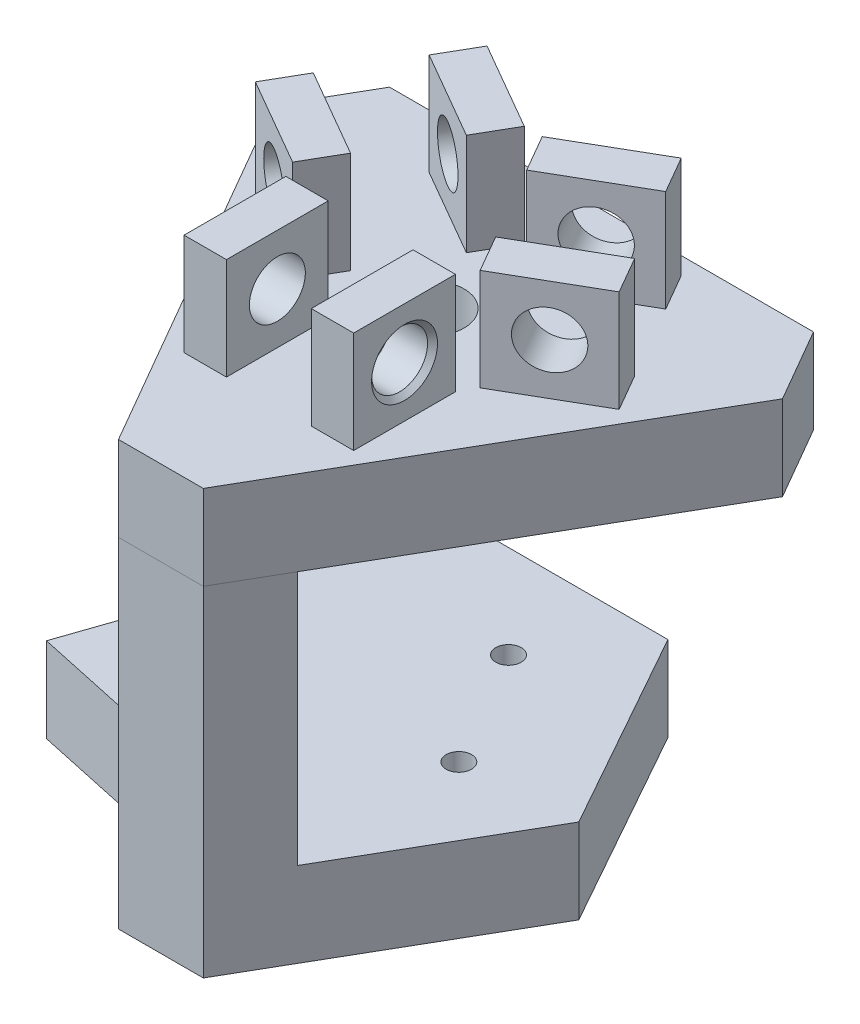
from build123d import *

# Parameters (mm, degrees)
EXTRUDE_1_DEPTH                 = 10
SKETCH_2_W                      = 5
SKETCH_2_H                      = 12
EXTRUDE_4_DEPTH                 = 12
HOLE_WIZARD_G1_16_1_D           = 6.6
HOLE_WIZARD_G1_16_1_DEPTH       = 50
HOLE_WIZARD_G1_16_1_CSINK_D     = 7.773
HOLE_WIZARD_G1_16_1_CSINK_ANGLE = 90
HOLE_WIZARD_G1_16_1_TIP         = 1.982840043
HOLE_WIZARD_G1_16_2_D           = 6.6
HOLE_WIZARD_G1_16_2_DEPTH       = 50
HOLE_WIZARD_G1_16_2_CSINK_D     = 7.773
HOLE_WIZARD_G1_16_2_CSINK_ANGLE = 90
HOLE_WIZARD_G1_16_2_TIP         = 1.982840043
HOLE_WIZARD_G1_16_3_D           = 6.6
HOLE_WIZARD_G1_16_3_DEPTH       = 50
HOLE_WIZARD_G1_16_3_CSINK_D     = 7.773
HOLE_WIZARD_G1_16_3_CSINK_ANGLE = 90
HOLE_WIZARD_G1_16_3_TIP         = 1.982840043
EXTRUDE_5_DEPTH                 = 40
SKETCH_19_W                     = 50
SKETCH_19_H                     = 30
CUT_EXTRUDE_2_DEPTH             = 74
EXTRUDE_6_DEPTH                 = 40
SKETCH_23_R                     = 1.5
CUT_EXTRUDE_3_DEPTH             = 6
SKETCH_24_R                     = 4
CUT_EXTRUDE_4_DEPTH             = 14
SPLIT_BODIES_1_SURFACE_1_BACK   = 101.717
SPLIT_BODIES_1_SURFACE_1_DEPTH  = 203.434
SPLIT_BODIES_1_SURFACE_2_BACK   = 101.717
SPLIT_BODIES_1_SURFACE_2_DEPTH  = 203.434


with BuildPart() as part:
    # 草图1 → 凸台-拉伸1 (new body)
    with BuildSketch(Plane(origin=(0, 0, 0), x_dir=(1, 0, 0), z_dir=(0, 1, 0))):
        Polygon((-32.831152269, 24.637065757), (17.168847731, 24.637065757), (22.168847731, 15.976811719), (-2.831152269, -27.32445847), (-12.831152269, -27.32445847), (-37.831152269, 15.976811719), align=None)
    extrude(amount=EXTRUDE_1_DEPTH)

    # 草图2 → 凸台-拉伸4 (add)
    with BuildSketch(Plane(origin=(0, 10, 0), x_dir=(1, 0, 0), z_dir=(0, 1, 0))):
        Polygon((-18.888926711, -0.733069557), (-16.388914662, 3.597050504), (-26.78120281, 9.597079424), (-29.28121486, 5.266959362), align=None)
        Polygon((-11.388890562, 12.257290628), (-8.888878512, 16.58741069), (-19.28116666, 22.58743961), (-21.78117871, 18.257319548), align=None)
        Polygon((-4.273413977, 12.257290628), (6.118874171, 18.257319548), (3.618862121, 22.58743961), (-6.773426027, 16.58741069), align=None)
        Polygon((3.226622172, -0.733069557), (13.618910321, 5.266959362), (11.118898271, 9.597079424), (0.726610123, 3.597050504), align=None)
        with Locations((-0.331152269, -8.591935763)):
            Rectangle(SKETCH_2_W, SKETCH_2_H)
        with Locations((-15.331152269, -8.591935763)):
            Rectangle(SKETCH_2_W, SKETCH_2_H)
    extrude(amount=EXTRUDE_4_DEPTH)

    # G1/16 螺纹孔1
    with Locations(Plane(origin=(4.96034155, 0, -8.591508373), x_dir=(-0.8660240123793532, 0, -0.500002409976558), z_dir=(0.500002409976558, 0, -0.8660240123793532))):
        with Locations((21.991727555, 16)):
            CounterSinkHole(HOLE_WIZARD_G1_16_1_D / 2, HOLE_WIZARD_G1_16_1_CSINK_D / 2, depth=HOLE_WIZARD_G1_16_1_DEPTH, counter_sink_angle=HOLE_WIZARD_G1_16_1_CSINK_ANGLE)
            with Locations((0, 0, -(HOLE_WIZARD_G1_16_1_DEPTH + HOLE_WIZARD_G1_16_1_TIP / 2))):  # 118° drill point
                Cone(0, HOLE_WIZARD_G1_16_1_D / 2, HOLE_WIZARD_G1_16_1_TIP, mode=Mode.SUBTRACT)

    # G1/16 螺纹孔2
    with Locations(Plane(origin=(-8.875955431, 0, -15.373506972), x_dir=(-0.8660240123793504, 0, 0.5000024099765628), z_dir=(-0.5000024099765628, 0, -0.8660240123793506))):
        with Locations((-8.427795735, 16)):
            CounterSinkHole(HOLE_WIZARD_G1_16_2_D / 2, HOLE_WIZARD_G1_16_2_CSINK_D / 2, depth=HOLE_WIZARD_G1_16_2_DEPTH, counter_sink_angle=HOLE_WIZARD_G1_16_2_CSINK_ANGLE)
            with Locations((0, 0, -(HOLE_WIZARD_G1_16_2_DEPTH + HOLE_WIZARD_G1_16_2_TIP / 2))):  # 118° drill point
                Cone(0, HOLE_WIZARD_G1_16_2_D / 2, HOLE_WIZARD_G1_16_2_TIP, mode=Mode.SUBTRACT)

    # G1/16 螺纹孔3
    with Locations(Plane(origin=(2.168847731, 0, 0), x_dir=(0, 0, -1), z_dir=(1, 0, 0))):
        with Locations((-8.591935763, 16)):
            CounterSinkHole(HOLE_WIZARD_G1_16_3_D / 2, HOLE_WIZARD_G1_16_3_CSINK_D / 2, depth=HOLE_WIZARD_G1_16_3_DEPTH, counter_sink_angle=HOLE_WIZARD_G1_16_3_CSINK_ANGLE)
            with Locations((0, 0, -(HOLE_WIZARD_G1_16_3_DEPTH + HOLE_WIZARD_G1_16_3_TIP / 2))):  # 118° drill point
                Cone(0, HOLE_WIZARD_G1_16_3_D / 2, HOLE_WIZARD_G1_16_3_TIP, mode=Mode.SUBTRACT)

    # 草图18 → 凸台-拉伸5 (add)
    with BuildSketch(Plane(origin=(0, 0, 0), x_dir=(-1, 0, 0), z_dir=(0, -1, 0))):
        Polygon((36.516059441, -12.131432542), (30.961139109, 4.077599876), (19.480871434, -15.806807021), align=None)
        Polygon((30.961139109, 4.077599876), (23.915302437, 24.637065757), (-1.237762159, -20.276891949), (19.480871434, -15.806807021), align=None)
        Polygon((23.915302437, 24.637065757), (0, 24.637065757), (-13.377530598, 0.749803781), (-1.237762159, -20.276891949), align=None)
    extrude(amount=EXTRUDE_5_DEPTH)

    # 草图19 → 切除-拉伸2 (cut)
    with BuildSketch(Plane(origin=(-4.125141126, 0, 19.119835281), x_dir=(0.9775078175150543, 0, 0.21089918609837094), z_dir=(-0.21089918609837097, 0, 0.9775078175150544))):
        with Locations((-8.136224319, -15)):
            Rectangle(SKETCH_19_W, SKETCH_19_H)
    extrude(amount=-CUT_EXTRUDE_2_DEPTH, mode=Mode.SUBTRACT)


with BuildPart() as cut_extrude_2_piece_1:
    # of the separate pieces the step leaves, piece 1, a body of its own (cut_extrude_2_pieces)
    add(part.part.solids().sort_by_distance((17.168847731, 0, -24.637065757))[0])



with BuildPart() as cut_extrude_2_piece_2:
    # of the separate pieces the step leaves, piece 2, a body of its own (cut_extrude_2_pieces)
    add(part.part.solids().sort_by_distance((-23.915302437, -30, -24.637065757))[0])


with BuildPart() as cut_extrude_2_piece_1_1:
    add(cut_extrude_2_piece_1.part)

    add(cut_extrude_2_piece_2.part)  # 凸台-拉伸6 merges 切除-拉伸2 piece 2
    # 草图20 → 凸台-拉伸6 (add)
    with BuildSketch(Plane.XZ):
        Polygon((-12.831152269, 27.32445847), (-19.480871434, 15.806807021), (1.237762159, 20.276891949), (-2.831152269, 27.32445847), align=None)
        Polygon((-37.831152269, -15.976811719), (-30.961139109, -4.077599876), (-23.915302437, -24.637065757), (-32.831152269, -24.637065757), align=None)
    extrude(amount=EXTRUDE_6_DEPTH)

    # 草图23 → 切除-拉伸3 (cut)
    with BuildSketch(Plane(origin=(0, -30, 0), x_dir=(1, 0, 0), z_dir=(0, 1, 0))):
        with Locations(Location((0.168847731, -0.188995818, 0), (0, 0, 270))):
            Circle(SKETCH_23_R)
        with Locations(Location((-7.831152269, 13.667410642, 0), (0, 0, 270))):
            Circle(SKETCH_23_R)
    extrude(amount=-CUT_EXTRUDE_3_DEPTH, mode=Mode.SUBTRACT)

    # 草图24 → 切除-拉伸4 (cut)
    with BuildSketch(Plane(origin=(0, 10, 0), x_dir=(1, 0, 0), z_dir=(0, 1, 0))):
        with Locations(Location((-7.831152269, 4.429806335, 0), (0, 0, 270))):
            Circle(SKETCH_24_R)
    extrude(amount=-CUT_EXTRUDE_4_DEPTH, mode=Mode.SUBTRACT)


with BuildPart() as body_2:
    # Split Bodies 1: the piece behind the surface
    add(cut_extrude_2_piece_1_1.part)
    # Split Bodies 1 surface: a surface, the sketch's curves swept straight by 203.434 mm
    with BuildLine(Plane(origin=(-35.291526612, 0, -20.37557239), x_dir=(-0.4999999999999961, 0, 0.866025403784441), z_dir=(-0.866025403784441, 0, -0.4999999999999961)).offset(-SPLIT_BODIES_1_SURFACE_1_BACK), mode=Mode.PRIVATE) as split_bodies_1_surface_1_path:
        Line((-9.378673602, 0), (48.060747663, 0))
        Line((48.060747663, 0), (48.060747663, -0.001))
        Line((48.060747663, -0.001), (-9.378673602, -0.001))
        Line((-9.378673602, -0.001), (-9.378673602, 0))
    split_bodies_1_surface_1 = Shell.extrude(split_bodies_1_surface_1_path.wire(), (-0.866025404 * SPLIT_BODIES_1_SURFACE_1_DEPTH, 0 * SPLIT_BODIES_1_SURFACE_1_DEPTH, -0.5 * SPLIT_BODIES_1_SURFACE_1_DEPTH))
    split(bisect_by=split_bodies_1_surface_1, keep=Keep.BOTTOM)


with BuildPart() as cut_extrude_2_piece_1_2:
    add(cut_extrude_2_piece_1_1.part)

    # Split Bodies 1: split by a surface, the side it looks to stays
    # Split Bodies 1 surface: a surface, the sketch's curves swept straight by 203.434 mm
    with BuildLine(Plane(origin=(-35.291526612, 0, -20.37557239), x_dir=(-0.4999999999999961, 0, 0.866025403784441), z_dir=(-0.866025403784441, 0, -0.4999999999999961)).offset(-SPLIT_BODIES_1_SURFACE_2_BACK), mode=Mode.PRIVATE) as split_bodies_1_surface_2_path:
        Line((-9.378673602, 0), (48.060747663, 0))
        Line((48.060747663, 0), (48.060747663, -0.001))
        Line((48.060747663, -0.001), (-9.378673602, -0.001))
        Line((-9.378673602, -0.001), (-9.378673602, 0))
    split_bodies_1_surface_2 = Shell.extrude(split_bodies_1_surface_2_path.wire(), (-0.866025404 * SPLIT_BODIES_1_SURFACE_2_DEPTH, 0 * SPLIT_BODIES_1_SURFACE_2_DEPTH, -0.5 * SPLIT_BODIES_1_SURFACE_2_DEPTH))
    split(bisect_by=split_bodies_1_surface_2, keep=Keep.TOP)


solid = Compound([body_2.part, cut_extrude_2_piece_1_2.part])
